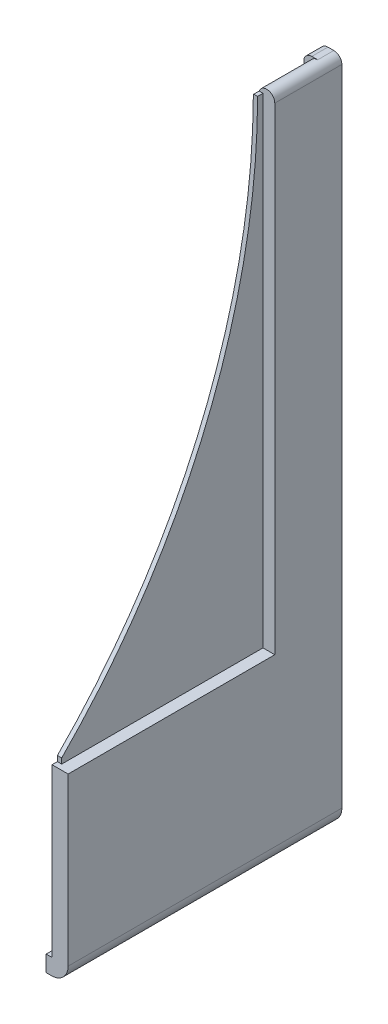
from build123d import *

# Parameters (mm, degrees)
CROQUIS1_W              = 1
CROQUIS1_H              = 3
SALIENTE_EXTRUIR1_DEPTH = 48
SALIENTE_EXTRUIR2_DEPTH = 3
CROQUIS3_W              = 38.5
CROQUIS3_H              = 90.5
CORTAR_EXTRUIR1_DEPTH   = 2.2
CORTAR_EXTRUIR2_DEPTH   = 2.9


with BuildPart() as part:
    # Croquis1 → Saliente-Extruir1 (new body)
    with BuildSketch(Plane.XY):
        with BuildLine():
            ThreePointArc((1.1, 120.1), (2.6, 121.6), (4.1, 120.1))
            Line((4.1, 120.1), (4.1, 0.1))
            Line((4.1, 0.1), (1.1, 0.1))
            Line((1.1, 0.1), (1.1, 120.1))
        make_face()
        with BuildLine():
            Line((1, 0), (1, -3))
            ThreePointArc((1, -3), (3.192031022, -2.092031022), (4.1, 0.1))
            Line((4.1, 0.1), (1.1, 0.1))
            ThreePointArc((1.1, 0.1), (1.070710678, 0.029289322), (1, 0))
        make_face()
        with Locations((0.5, -1.5)):
            Rectangle(CROQUIS1_W, CROQUIS1_H)
    extrude(amount=SALIENTE_EXTRUIR1_DEPTH)

    # Croquis2 → Saliente-Extruir2 (add)
    with BuildSketch(Plane(origin=(0, 0, 0), x_dir=(-1, 0, 0), z_dir=(0, 0, -1))):
        with BuildLine():
            Line((-1, -3), (0, -3))
            Line((0, -3), (0, 120.1))
            ThreePointArc((0, 120.1), (-0.439339828, 121.160660172), (-1.5, 121.6))
            Line((-1.5, 121.6), (-2.6, 121.6))
            ThreePointArc((-2.6, 121.6), (-3.660660172, 121.160660172), (-4.1, 120.1))
            Line((-4.1, 120.1), (-4.1, 0.1))
            ThreePointArc((-4.1, 0.1), (-3.192031022, -2.092031022), (-1, -3))
        make_face()
    extrude(amount=SALIENTE_EXTRUIR2_DEPTH)

    # Croquis3 → Cortar-Extruir1 (cut)
    with BuildSketch(Plane(origin=(4.1, 0, 0), x_dir=(0, 0, -1), z_dir=(1, 0, 0))):
        with Locations((-28.75, 76.35)):
            Rectangle(CROQUIS3_W, CROQUIS3_H)
    extrude(amount=-CORTAR_EXTRUIR1_DEPTH, mode=Mode.SUBTRACT)

    # Croquis4 → Cortar-Extruir2 (cut, through all)
    with BuildSketch(Plane(origin=(1.9, 0, 0), x_dir=(0, 0, -1), z_dir=(1, 0, 0))):
        with BuildLine():
            Line((-9.5, 120.6), (-9.5, 121.426649916))
            Line((-9.5, 121.426649916), (-48, 121.426649916))
            Line((-48, 121.426649916), (-48, 31.1))
            Line((-48, 31.1), (-47, 31.1))
            Line((-47, 31.1), (-47, 32.1))
            ThreePointArc((-47, 32.1), (-19.983171743, 72.73430247), (-10.5, 120.6))
            Line((-10.5, 120.6), (-9.5, 120.6))
        make_face()
    extrude(amount=-CORTAR_EXTRUIR2_DEPTH, mode=Mode.SUBTRACT)


solid = part.part
